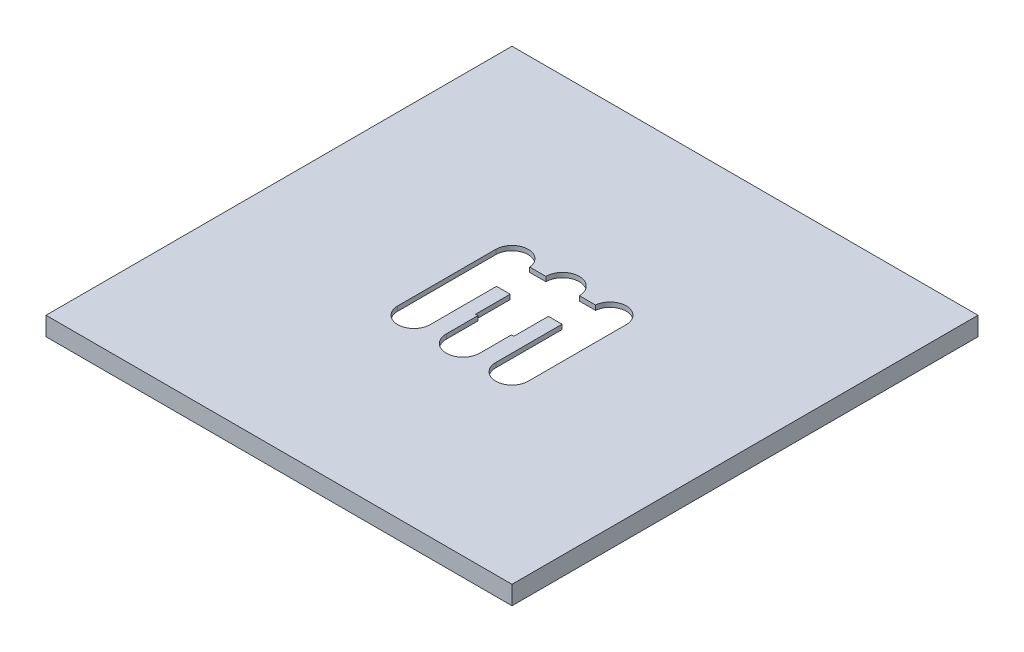
from build123d import *

# Parameters (mm, degrees)
SKETCH1_W           = 100
SKETCH1_H           = 100
SKETCH1_W_2         = 96
SKETCH1_H_2         = 96
BOSS_EXTRUDE1_DEPTH = 3
SKETCH2_W           = 100
SKETCH2_H           = 100
BOSS_EXTRUDE2_DEPTH = 1
CUT_EXTRUDE1_DEPTH  = 1


with BuildPart() as part:
    # Sketch1 → Boss-Extrude1 (new body)
    with BuildSketch(Plane(origin=(0, 0, 0), x_dir=(1, 0, 0), z_dir=(0, 1, 0))):
        Rectangle(SKETCH1_W, SKETCH1_H)
        Rectangle(SKETCH1_W_2, SKETCH1_H_2, mode=Mode.SUBTRACT)
    extrude(amount=BOSS_EXTRUDE1_DEPTH)

    # Sketch2 → Boss-Extrude2 (add)
    with BuildSketch(Plane(origin=(0, 3, 0), x_dir=(1, 0, 0), z_dir=(0, 1, 0))):
        Rectangle(SKETCH2_W, SKETCH2_H)
    extrude(amount=BOSS_EXTRUDE2_DEPTH)

    # Sketch3 → Cut-Extrude1 (cut)
    with BuildSketch(Plane.XZ.offset(-3)):
        with BuildLine():
            Line((-7.034769829, -3.709104883), (-7.034769829, 10.517384915))
            ThreePointArc((-7.034769829, 10.517384915), (-10.517384915, 14), (-14, 10.517384915))
            Line((-14, 10.517384915), (-14, -10.517384915))
            ThreePointArc((-14, -10.517384915), (-10.687570013, -13.995839293), (-7.051402714, -10.857348469))
            Line((-7.051402714, -10.857348469), (-3.591574507, -10.857348469))
            ThreePointArc((-3.591574507, -10.857348469), (0, -14.448922976), (3.591574507, -10.857348469))
            Line((3.591574507, -10.857348469), (7.051402714, -10.857348469))
            ThreePointArc((7.051402714, -10.857348469), (10.687570013, -13.995839293), (14, -10.517384915))
            Line((14, -10.517384915), (14, 10.517384915))
            ThreePointArc((14, 10.517384915), (10.517384915, 14), (7.034769829, 10.517384915))
            Line((7.034769829, 10.517384915), (7.034769829, -3.709104883))
            Line((7.034769829, -3.709104883), (4.104776873, -3.709104883))
            Line((4.104776873, -3.709104883), (4.104776873, 3.709104883))
            Line((4.104776873, 3.709104883), (3.591574507, 3.709104883))
            Line((3.591574507, 3.709104883), (3.591574507, 10.517384915))
            ThreePointArc((3.591574507, 10.517384915), (0, 14.108959421), (-3.591574507, 10.517384915))
            Line((-3.591574507, 10.517384915), (-3.591574507, 3.709104883))
            Line((-3.591574507, 3.709104883), (-4.104776873, 3.709104883))
            Line((-4.104776873, 3.709104883), (-4.104776873, -3.709104883))
            Line((-4.104776873, -3.709104883), (-7.034769829, -3.709104883))
        make_face()
    extrude(amount=-CUT_EXTRUDE1_DEPTH, mode=Mode.SUBTRACT)


solid = part.part
